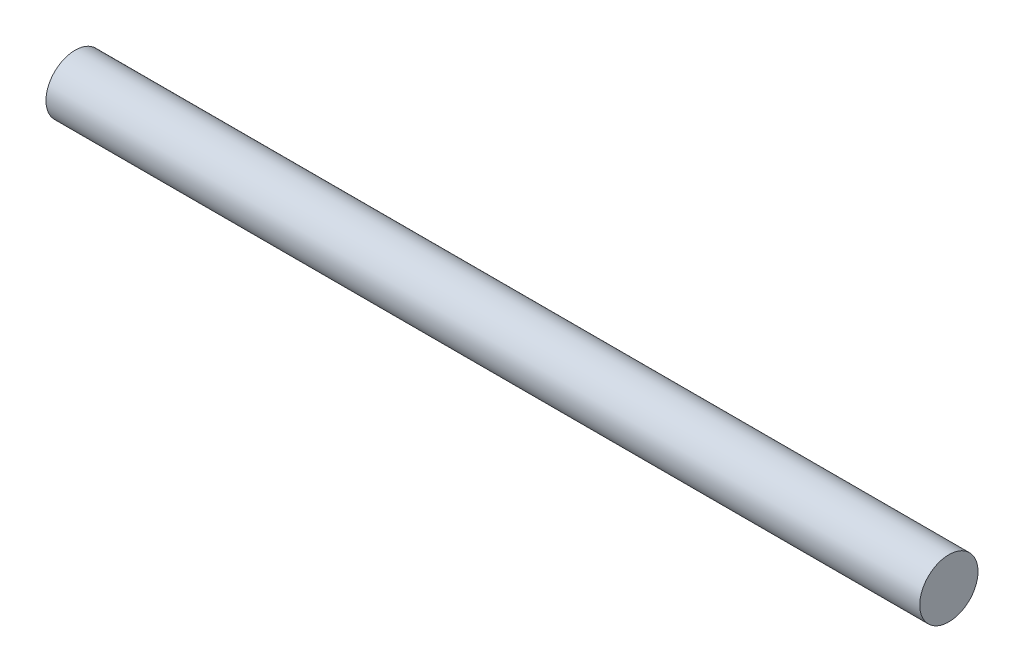
from build123d import *

# Parameters (mm, degrees)
SKETCH_1_R      = 5
EXTRUDE_1_DEPTH = 150


with BuildPart() as part:
    # 草图1 → 凸台-拉伸1 (new body)
    with BuildSketch(Plane(origin=(0, 0, 0), x_dir=(0, 0, -1), z_dir=(1, 0, 0))):
        Circle(SKETCH_1_R)
    extrude(amount=EXTRUDE_1_DEPTH)


solid = part.part
